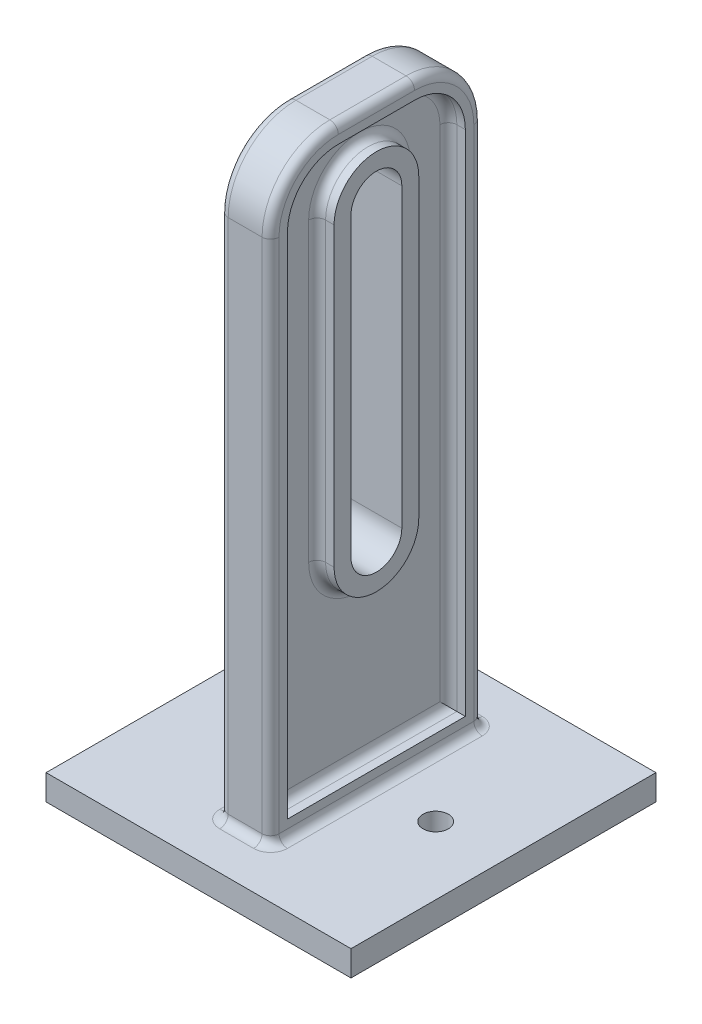
from build123d import *

# Parameters (mm, degrees)
SKETCH1_W           = 36
SKETCH1_H           = 36
BOSS_EXTRUDE1_DEPTH = 3
SKETCH2_R           = 1.5
CUT_EXTRUDE1_DEPTH  = 3
SKETCH3_W           = 6
SKETCH3_H           = 25
BOSS_EXTRUDE2_DEPTH = 70
CUT_EXTRUDE2_DEPTH  = 70
FILLET1_R           = 8
CUT_EXTRUDE5_DEPTH  = 2
FILLET3_R           = 1
FILLET4_R           = 1
FILLET5_R           = 1


with BuildPart() as part:
    # Sketch1 → Boss-Extrude1 (new body)
    with BuildSketch(Plane(origin=(0, 0, 0), x_dir=(1, 0, 0), z_dir=(0, 1, 0))):
        Rectangle(SKETCH1_W, SKETCH1_H)
    extrude(amount=BOSS_EXTRUDE1_DEPTH)

    # Sketch2 → Cut-Extrude1 (cut)
    with BuildSketch(Plane(origin=(0, 3, 0), x_dir=(1, 0, 0), z_dir=(0, 1, 0))):
        with Locations((-10, 0)):
            Circle(SKETCH2_R)
        with Locations((10, 0)):
            Circle(SKETCH2_R)
    extrude(amount=-CUT_EXTRUDE1_DEPTH, mode=Mode.SUBTRACT)

    # Sketch3 → Boss-Extrude2 (add)
    with BuildSketch(Plane(origin=(0, 3, 0), x_dir=(1, 0, 0), z_dir=(0, 1, 0))):
        Rectangle(SKETCH3_W, SKETCH3_H)
    extrude(amount=BOSS_EXTRUDE2_DEPTH)

    # Sketch4 → Cut-Extrude2 (cut)
    with BuildSketch(Plane(origin=(3, 0, 0), x_dir=(0, 0, -1), z_dir=(1, 0, 0))):
        with BuildLine():
            Line((3, 63), (3, 28))
            ThreePointArc((3, 28), (0, 25), (-3, 28))
            Line((-3, 28), (-3, 63))
            ThreePointArc((-3, 63), (0, 66), (3, 63))
        make_face()
    extrude(amount=-CUT_EXTRUDE2_DEPTH, mode=Mode.SUBTRACT)

    # Fillet1
    fillet1_edges = [part.edges().sort_by_distance(p)[0] for p in [
        (0, 73, 12.5),
        (0, 73, -12.5),
    ]]
    fillet(fillet1_edges, radius=FILLET1_R)

    # Sketch8 → Cut-Extrude5 (cut)
    with BuildSketch(Plane(origin=(3, 0, 0), x_dir=(0, 0, -1), z_dir=(1, 0, 0))):
        with BuildLine():
            Line((-10.5, 65), (-10.5, 5))
            Line((-10.5, 5), (10.5, 5))
            Line((10.5, 5), (10.5, 65))
            ThreePointArc((10.5, 65), (8.742640687, 69.242640687), (4.5, 71))
            Line((4.5, 71), (-4.5, 71))
            ThreePointArc((-4.5, 71), (-8.742640687, 69.242640687), (-10.5, 65))
        make_face()
        with BuildLine():
            Line((5, 63), (5, 28))
            ThreePointArc((5, 28), (0, 23), (-5, 28))
            Line((-5, 28), (-5, 63))
            ThreePointArc((-5, 63), (0, 68), (5, 63))
        make_face(mode=Mode.SUBTRACT)
    cut_extrude5 = extrude(amount=-CUT_EXTRUDE5_DEPTH, mode=Mode.SUBTRACT)

    # Mirror1: Cut-Extrude5 across plane
    add(cut_extrude5.mirror(Plane(origin=(0, 0, 0), x_dir=(0, 0, 1), z_dir=(1, 0, 0))), mode=Mode.SUBTRACT)

    # Fillet3
    fillet3_edges = [part.edges().sort_by_distance(p)[0] for p in [
        (-3, 73, 0),
        (3, 73, 0),
        (-3, 34, 12.5),
        (-3, 34, -12.5),
        (-3, 70.656854249, 10.156854249),
        (-3, 70.656854249, -10.156854249),
        (3, 34, -12.5),
        (3, 34, 12.5),
        (3, 70.656854249, 10.156854249),
        (3, 70.656854249, -10.156854249),
    ]]
    fillet(fillet3_edges, radius=FILLET3_R)

    # Fillet4
    fillet4_edges = [part.edges().sort_by_distance(p)[0] for p in [
        (-1, 5, 0),
        (-1, 35, -10.5),
        (-1, 69.242640687, -8.742640687),
        (-1, 71, 0),
        (-1, 69.242640687, 8.742640687),
        (-1, 35, 10.5),
        (-1, 23, 0),
        (-1, 45.5, -5),
        (-1, 68, 0),
        (-1, 45.5, 5),
        (1, 5, 0),
        (1, 35, 10.5),
        (1, 69.242640687, 8.742640687),
        (1, 71, 0),
        (1, 69.242640687, -8.742640687),
        (1, 35, -10.5),
        (1, 23, 0),
        (1, 45.5, -5),
        (1, 68, 0),
        (1, 45.5, 5),
    ]]
    fillet(fillet4_edges, radius=FILLET4_R)

    # Fillet5
    fillet5_edges = [part.edges().sort_by_distance(p)[0] for p in [
        (0, 3, 12.5),
        (-3, 3, 0),
        (0, 3, -12.5),
        (3, 3, 0),
        (-2.707106781, 3, 12.207106781),
        (-2.707106781, 3, -12.207106781),
        (2.707106781, 3, 12.207106781),
        (2.707106781, 3, -12.207106781),
    ]]
    fillet(fillet5_edges, radius=FILLET5_R)


solid = part.part
